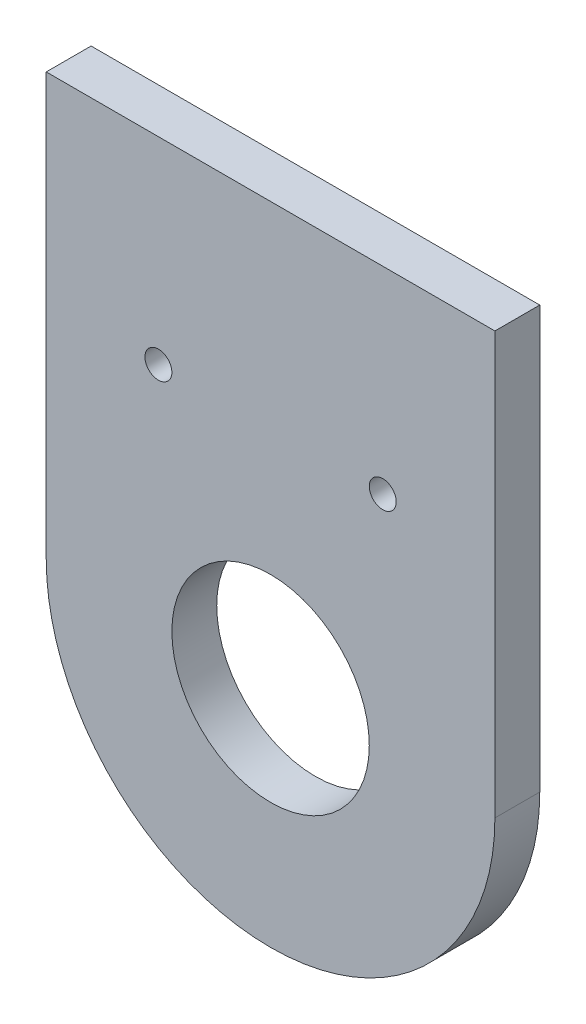
from build123d import *

# Parameters (mm, degrees)
ESQUISSE1_W             = 94
ESQUISSE1_H             = 93.807810261
ESQUISSE1_R             = 11
BOSS_EXTRU_1_DEPTH      = 5
ESQUISSE2_R             = 1.5
ENL_V_MAT_EXTRU_1_DEPTH = 67.655832453


with BuildPart() as part:
    # Esquisse1 → Boss.-Extru.1 (new body)
    with BuildSketch(Plane.XY):
        with Locations((0, 0.096094869)):
            Rectangle(ESQUISSE1_W, ESQUISSE1_H)
        Circle(ESQUISSE1_R, mode=Mode.SUBTRACT)
    extrude(amount=BOSS_EXTRU_1_DEPTH)

    # Esquisse2 → Enlèv. mat.-Extru.1 (cut, through all)
    with BuildSketch(Plane.XY.offset(5)):
        with BuildLine():
            Line((25, 47), (25, 0))
            ThreePointArc((25, 0), (0, -25), (-25, 0))
            Line((-25, 0), (-25, 47))
            Line((-25, 47), (-47, 47))
            Line((-47, 47), (-47, -46.807810261))
            Line((-47, -46.807810261), (47, -46.807810261))
            Line((47, -46.807810261), (47, 47))
            Line((47, 47), (25, 47))
        make_face()
        with Locations((-12.5, 25)):
            Circle(ESQUISSE2_R)
        with Locations((12.5, 25)):
            Circle(ESQUISSE2_R)
    extrude(amount=-ENL_V_MAT_EXTRU_1_DEPTH, mode=Mode.SUBTRACT)


solid = part.part
